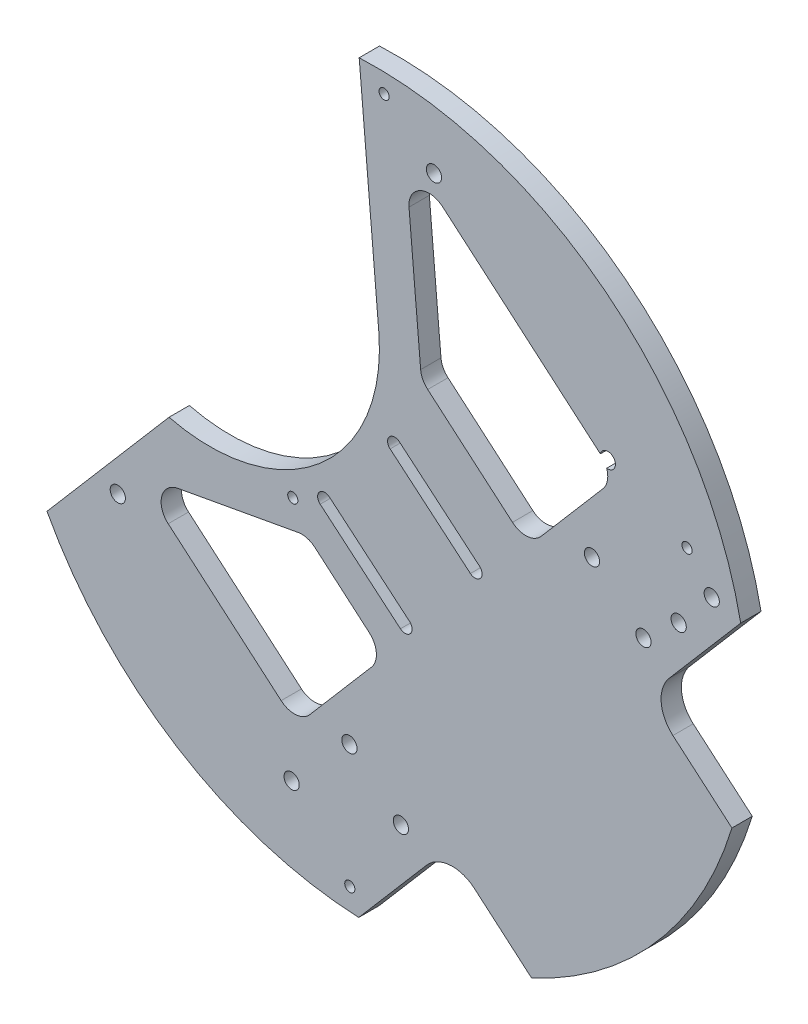
from build123d import *

# Parameters (mm, degrees)
SKETCH1_R                     = 2.25
BOSS_EXTRUDE1_DEPTH           = 6
CUT_EXTRUDE1_DEPTH            = 10
F_4_5_4_5_DIAMETER_HOLE_D     = 4.5
F_4_5_4_5_DIAMETER_HOLE_DEPTH = 10
F_4_5_4_5_DIAMETER_HOLE_TIP   = 1.351936393
F_3_0MM_DOWEL_HOLE1_D         = 3
SKETCH7_R                     = 2.25
CUT_EXTRUDE2_DEPTH            = 10


with BuildPart() as part:
    # Sketch1 → Boss-Extrude1 (new body)
    with BuildSketch(Plane.XY):
        with BuildLine():
            Line((-65.035663909, 1.711915541), (-29.013741643, 43.763540838))
            ThreePointArc((-29.013741643, 43.763540838), (15.528638553, 54.242344325), (32.891210702, 96.578735816))
            Line((32.891210702, 96.578735816), (27.09893981, 163.698257544))
            ThreePointArc((27.09893981, 163.698257544), (127.465162664, -0.583384595), (-65.035663909, 1.711915541))
        make_face()
        with Locations((-44.130722543, 16.588386381)):
            Circle(SKETCH1_R, mode=Mode.SUBTRACT)
        with Locations((7.160790579, -31.047531597)):
            Circle(SKETCH1_R, mode=Mode.SUBTRACT)
        with Locations((100.470270724, 97.551800763)):
            Circle(SKETCH1_R, mode=Mode.SUBTRACT)
        with Locations((49.178757602, 145.187718741)):
            Circle(SKETCH1_R, mode=Mode.SUBTRACT)
    extrude(amount=BOSS_EXTRUDE1_DEPTH)

    # Sketch2 → Cut-Extrude1 (cut)
    with BuildSketch(Plane.XY.offset(6)):
        with BuildLine():
            Line((59.918631336, 48.293162369), (36.232435894, 68.292265986))
            ThreePointArc((36.232435894, 68.292265986), (35.982665158, 71.251592696), (38.941991868, 71.501363433))
            Line((38.941991868, 71.501363433), (62.62818731, 51.502259816))
            ThreePointArc((62.62818731, 51.502259816), (62.877958047, 48.542933105), (59.918631336, 48.293162369))
        make_face()
        with BuildLine():
            Line((39.274395345, 23.842896106), (15.588199903, 43.841999723))
            ThreePointArc((15.588199903, 43.841999723), (15.338429166, 46.801326433), (18.297755877, 47.05109717))
            Line((18.297755877, 47.05109717), (41.983951319, 27.051993553))
            ThreePointArc((41.983951319, 27.051993553), (42.233722055, 24.092666842), (39.274395345, 23.842896106))
        make_face()
    extrude(amount=-CUT_EXTRUDE1_DEPTH, mode=Mode.SUBTRACT)

    # Ø4.5 (4.5) Diameter Hole
    with Locations(Plane(origin=(207.215806152, -96.41995806, 6), x_dir=(-0.650558884, -0.759455817, 0), z_dir=(0, 0, 1))):
        with Locations((80.500098125, -194.461558154), (77.690872648, -264.405165812), (-80.677949684, -277.202176468), (-77.868724207, -207.25856881)):
            Hole(F_4_5_4_5_DIAMETER_HOLE_D / 2, depth=F_4_5_4_5_DIAMETER_HOLE_DEPTH)
            with Locations((0, 0, -(F_4_5_4_5_DIAMETER_HOLE_DEPTH + F_4_5_4_5_DIAMETER_HOLE_TIP / 2))):  # 118° drill point
                Cone(0, F_4_5_4_5_DIAMETER_HOLE_D / 2, F_4_5_4_5_DIAMETER_HOLE_TIP, mode=Mode.SUBTRACT)

    # Ø3.0mm Dowel Hole1 (through all)
    with Locations(Plane(origin=(207.215806152, -96.41995806, 6), x_dir=(-0.650558884, -0.759455817, 0), z_dir=(0, 0, 1))):
        with Locations((-80.915811264, -296.794954316), (-84.945199209, -182.518931257), (25.216324899, -241.36407945), (83.328606401, -169.42446636)):
            Hole(F_3_0MM_DOWEL_HOLE1_D / 2)

    # Sketch7 → Cut-Extrude2 (cut)
    with BuildSketch(Plane.XY.offset(6)):
        with Locations((39.410270698, -26.198883172)):
            Circle(SKETCH7_R)
        with Locations((110.999824953, 57.374033532)):
            Circle(SKETCH7_R)
        with Locations((24.221154353, -13.187705491)):
            Circle(SKETCH7_R)
        with Locations((95.810708608, 70.385211214)):
            Circle(SKETCH7_R)
        with Locations((121.384198104, 66.422365269)):
            Circle(SKETCH7_R)
        with Locations((131.142581365, 77.814202528)):
            Circle(SKETCH7_R)
        with BuildLine():
            Line((41.803278926, 132.877815745), (45.238927964, 93.066293708))
            ThreePointArc((45.238927964, 93.066293708), (45.878980474, 90.841973124), (47.31335672, 89.025428586))
            Line((47.31335672, 89.025428586), (72.343619279, 67.584208031))
            ThreePointArc((72.343619279, 67.584208031), (76.708983142, 66.158757194), (80.803707486, 68.23758963))
            Line((80.803707486, 68.23758963), (99.019356241, 89.502352513))
            ThreePointArc((99.019356241, 89.502352513), (100.444807079, 93.867716376), (98.365974642, 97.962440721))
            Line((98.365974642, 97.962440721), (51.684414291, 137.95042043))
            ThreePointArc((51.684414291, 137.95042043), (45.040870621, 138.731415078), (41.803278926, 132.877815745))
        make_face()
        with BuildLine():
            Line((139.689194778, 75.494313025), (118.594383125, 50.868444691))
            ThreePointArc((118.594383125, 50.868444691), (116.218631729, 43.592838252), (119.683352457, 36.768297678))
            Line((119.683352457, 36.768297678), (137.105326674, 21.84442739))
            Line((137.105326674, 21.84442739), (157.179168696, 45.278426173))
            Line((157.179168696, 45.278426173), (139.689194778, 75.494313025))
        make_face()
        with BuildLine():
            Line((26.971727927, -56.090910074), (47.00482887, -32.704472013))
            ThreePointArc((47.00482887, -32.704472013), (53.829369443, -29.239751286), (61.104975883, -31.615502682))
            Line((61.104975883, -31.615502682), (77.970944185, -46.063091691))
            Line((77.970944185, -46.063091691), (19.420644617, -114.414115242))
            Line((19.420644617, -114.414115242), (26.971727927, -56.090910074))
        make_face()
        with BuildLine():
            Line((30.087133776, 18.254417116), (14.029920526, 32.00921693))
            ThreePointArc((14.029920526, 32.00921693), (11.691810194, 33.244719456), (9.049641571, 33.355043432))
            Line((9.049641571, 33.355043432), (-26.432830213, 26.881246485))
            ThreePointArc((-26.432830213, 26.881246485), (-31.148141992, 22.543928053), (-29.259257867, 16.421950176))
            Line((-29.259257867, 16.421950176), (4.064778412, -12.123815573))
            ThreePointArc((4.064778412, -12.123815573), (8.430142276, -13.549266411), (12.52486662, -11.470433974))
            Line((12.52486662, -11.470433974), (30.740515375, 9.794328908))
            ThreePointArc((30.740515375, 9.794328908), (32.165966213, 14.159692772), (30.087133776, 18.254417116))
        make_face()
    extrude(amount=-CUT_EXTRUDE2_DEPTH, mode=Mode.SUBTRACT)


solid = part.part
